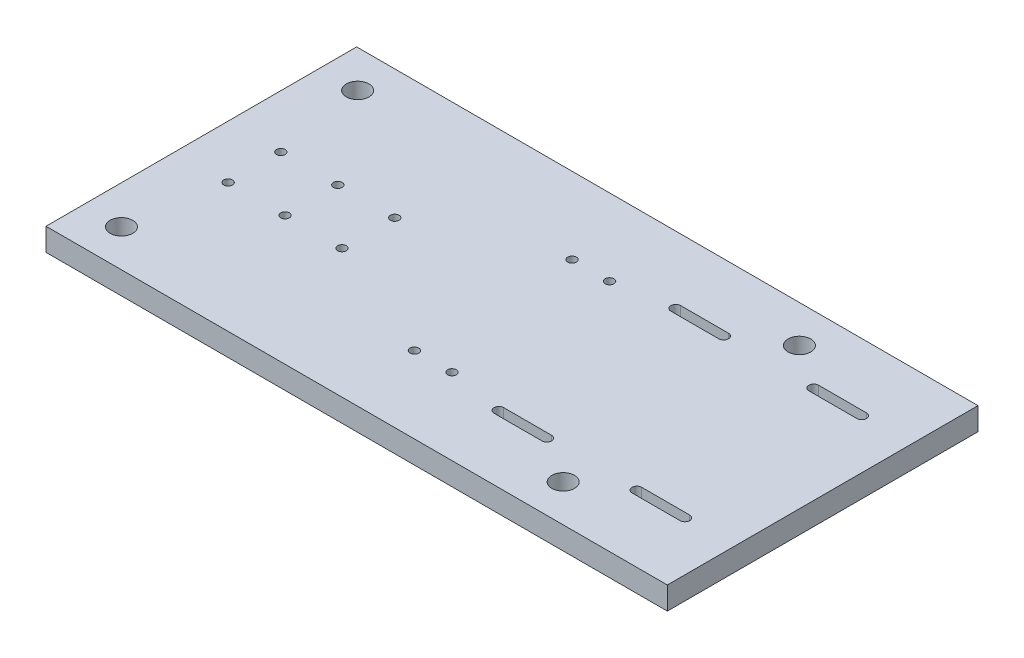
from build123d import *

# Parameters (mm, degrees)
SKETCH1_W                                      = 304.8
SKETCH1_H                                      = 152.4
BOSS_EXTRUDE1_DEPTH                            = 11.1125
CUT_EXTRUDE2_DEPTH                             = 11.1125
SKETCH10_R                                     = 5.55625
CUT_EXTRUDE9_DEPTH                             = 12.1125
CBORE_FOR_8_SOCKET_HEAD_CAP_SCREW1_D           = 4.3053
CBORE_FOR_8_SOCKET_HEAD_CAP_SCREW1_DEPTH       = 11.1125
CBORE_FOR_8_SOCKET_HEAD_CAP_SCREW1_CBORE_D     = 7.9375
CBORE_FOR_8_SOCKET_HEAD_CAP_SCREW1_CBORE_DEPTH = 4.1656
CBORE_FOR_8_SOCKET_HEAD_CAP_SCREW2_D           = 4.3053
CBORE_FOR_8_SOCKET_HEAD_CAP_SCREW2_DEPTH       = 11.1125
CBORE_FOR_8_SOCKET_HEAD_CAP_SCREW2_CBORE_D     = 7.9375
CBORE_FOR_8_SOCKET_HEAD_CAP_SCREW2_CBORE_DEPTH = 4.1656
CUT_EXTRUDE10_REACH                            = 119.196
SKETCH22_W                                     = 23.527686488
SKETCH22_H                                     = 2.54
SKETCH22_W_2                                   = 23.436556581


with BuildPart() as part:
    # Sketch1 → Boss-Extrude1 (new body)
    with BuildSketch(Plane(origin=(0, 0, 0), x_dir=(1, 0, 0), z_dir=(0, 1, 0))):
        with Locations((152.4, 76.2)):
            Rectangle(SKETCH1_W, SKETCH1_H)
    extrude(amount=BOSS_EXTRUDE1_DEPTH)

    # Sketch3 → Cut-Extrude2 (cut)
    with BuildSketch(Plane(origin=(0, 11.1125, 0), x_dir=(1, 0, 0), z_dir=(0, 1, 0))):
        with BuildLine():
            Line((280.567699438, 35.204123045), (257.04001295, 35.204123045))
            ThreePointArc((257.04001295, 35.204123045), (254.65876295, 32.822873045), (257.04001295, 30.441623045))
            Line((257.04001295, 30.441623045), (280.567699438, 30.441623045))
            ThreePointArc((280.567699438, 30.441623045), (282.948949438, 32.822873045), (280.567699438, 35.204123045))
        make_face()
        with BuildLine():
            Line((257.04001295, 117.195876955), (280.567699438, 117.195876955))
            ThreePointArc((280.567699438, 117.195876955), (282.948949438, 119.577126955), (280.567699438, 121.958376955))
            Line((280.567699438, 121.958376955), (257.04001295, 121.958376955))
            ThreePointArc((257.04001295, 121.958376955), (254.65876295, 119.577126955), (257.04001295, 117.195876955))
        make_face()
        with BuildLine():
            Line((212.85998705, 121.958376955), (189.332300562, 121.958376955))
            ThreePointArc((189.332300562, 121.958376955), (186.951050562, 119.577126955), (189.332300562, 117.195876955))
            Line((189.332300562, 117.195876955), (212.85998705, 117.195876955))
            ThreePointArc((212.85998705, 117.195876955), (215.24123705, 119.577126955), (212.85998705, 121.958376955))
        make_face()
        with BuildLine():
            Line((212.85998705, 35.204123045), (189.332300562, 35.204123045))
            ThreePointArc((189.332300562, 35.204123045), (186.951050562, 32.822873045), (189.332300562, 30.441623045))
            Line((189.332300562, 30.441623045), (212.85998705, 30.441623045))
            ThreePointArc((212.85998705, 30.441623045), (215.24123705, 32.822873045), (212.85998705, 35.204123045))
        make_face()
    extrude(amount=-CUT_EXTRUDE2_DEPTH, mode=Mode.SUBTRACT)

    # Sketch10 → Cut-Extrude9 (cut, through all)
    with BuildSketch(Plane.XZ):
        with Locations((18.74955505, -134.149424539)):
            Circle(SKETCH10_R)
        with Locations((18.74955505, -18.250575461)):
            Circle(SKETCH10_R)
        with Locations((235.448687079, -134.149424539)):
            Circle(SKETCH10_R)
        with Locations((235.448687079, -18.250575461)):
            Circle(SKETCH10_R)
    extrude(amount=-CUT_EXTRUDE9_DEPTH, mode=Mode.SUBTRACT)

    # CBORE for #8 Socket Head Cap Screw1
    with Locations(Plane(origin=(143.1925, 0, -37.545187713), x_dir=(0, 0, -1), z_dir=(0, -1, 0))):
        with Locations((0, 0), (0, 18.415), (77.309624574, 18.415), (77.309624574, 0)):
            CounterBoreHole(CBORE_FOR_8_SOCKET_HEAD_CAP_SCREW1_D / 2, CBORE_FOR_8_SOCKET_HEAD_CAP_SCREW1_CBORE_D / 2, CBORE_FOR_8_SOCKET_HEAD_CAP_SCREW1_CBORE_DEPTH, depth=CBORE_FOR_8_SOCKET_HEAD_CAP_SCREW1_DEPTH)

    # CBORE for #8 Socket Head Cap Screw2
    with Locations(Plane(origin=(26.061945565, 0, -89.133574987), x_dir=(0, 0, -1), z_dir=(0, -1, 0))):
        with Locations((0, 0), (-25.867149974, 0), (-25.867149974, 27.94), (0, 27.94), (0, 55.88), (-25.867149974, 55.88)):
            CounterBoreHole(CBORE_FOR_8_SOCKET_HEAD_CAP_SCREW2_D / 2, CBORE_FOR_8_SOCKET_HEAD_CAP_SCREW2_CBORE_D / 2, CBORE_FOR_8_SOCKET_HEAD_CAP_SCREW2_CBORE_DEPTH, depth=CBORE_FOR_8_SOCKET_HEAD_CAP_SCREW2_DEPTH)

    # Sketch22 → Cut-Extrude10 (cut, up to next)
    with BuildSketch(Plane.XY.offset(-35.204123045), mode=Mode.PRIVATE) as cut_extrude10_sk1:
        with Locations((201.096143806, 1.27)):
            Rectangle(SKETCH22_W, SKETCH22_H)
    cut_extrude10_tool1 = extrude(cut_extrude10_sk1.sketch, amount=-CUT_EXTRUDE10_REACH, mode=Mode.PRIVATE) & part.part
    add(cut_extrude10_tool1.solids().sort_by_distance((201.096144, 1.27, -35.204123))[0], mode=Mode.SUBTRACT)
    # Sketch22 → Cut-Extrude10 (cut, up to next)
    with BuildSketch(Plane.XY.offset(-35.204123045), mode=Mode.PRIVATE) as cut_extrude10_sk2:
        with Locations((268.758291241, 1.27)):
            Rectangle(SKETCH22_W_2, SKETCH22_H)
    cut_extrude10_tool2 = extrude(cut_extrude10_sk2.sketch, amount=-CUT_EXTRUDE10_REACH, mode=Mode.PRIVATE) & part.part
    add(cut_extrude10_tool2.solids().sort_by_distance((268.758291, 1.27, -35.204123))[0], mode=Mode.SUBTRACT)


solid = part.part
